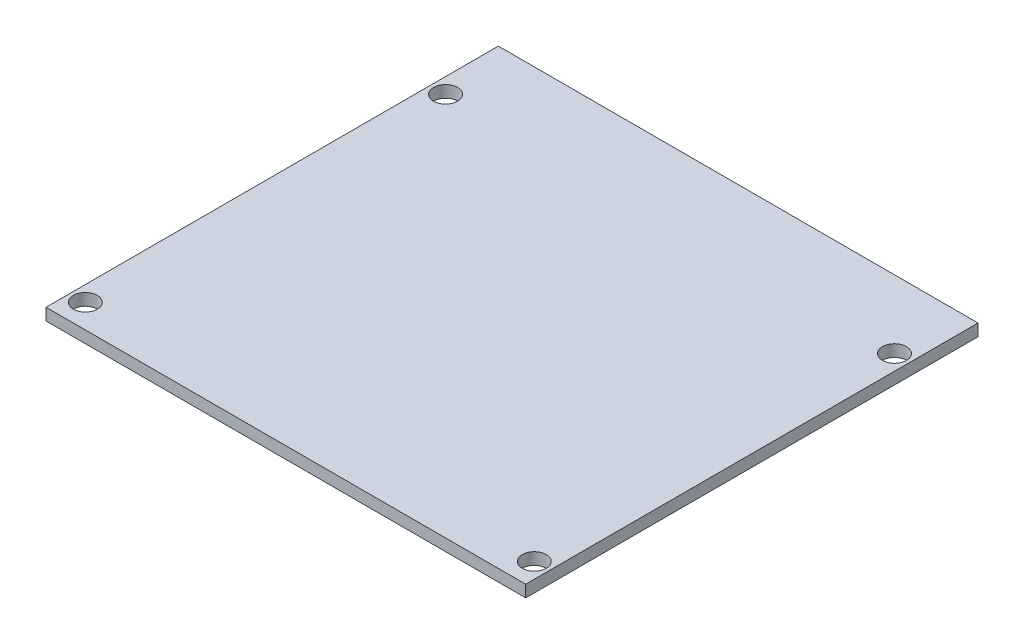
from build123d import *

# Parameters (mm, degrees)
SKETCH2_W               = 64.049999916
SKETCH2_H               = 60.400000104
BOSS_EXTRUDE1_DEPTH     = 0.79375
SKETCH3_R               = 1.599999975
CUT_EXTRUDE1_DEPTH      = 1.79375
CUT_EXTRUDE1_DEPTH_BACK = 1.79375


with BuildPart() as part:
    # Sketch2 → Boss-Extrude1 (new body, symmetric)
    with BuildSketch(Plane(origin=(0, 0, 0), x_dir=(1, 0, 0), z_dir=(0, 1, 0))):
        Rectangle(SKETCH2_W, SKETCH2_H)
    extrude(amount=BOSS_EXTRUDE1_DEPTH, both=True)

    # Sketch3 → Cut-Extrude1 (cut, two sides)
    with BuildSketch(Plane(origin=(0, 0, 0), x_dir=(1, 0, 0), z_dir=(0, 1, 0))) as cut_extrude1_sk:
        with Locations((-29.972, 21.099999964)):
            Circle(SKETCH3_R)
        with Locations((29.972, 21.099999964)):
            Circle(SKETCH3_R)
        with Locations((29.972, -27.000000102)):
            Circle(SKETCH3_R)
        with Locations((-29.972, -27.000000102)):
            Circle(SKETCH3_R)
    extrude(amount=CUT_EXTRUDE1_DEPTH, mode=Mode.SUBTRACT)
    extrude(cut_extrude1_sk.sketch, amount=-CUT_EXTRUDE1_DEPTH_BACK, mode=Mode.SUBTRACT)


solid = part.part
